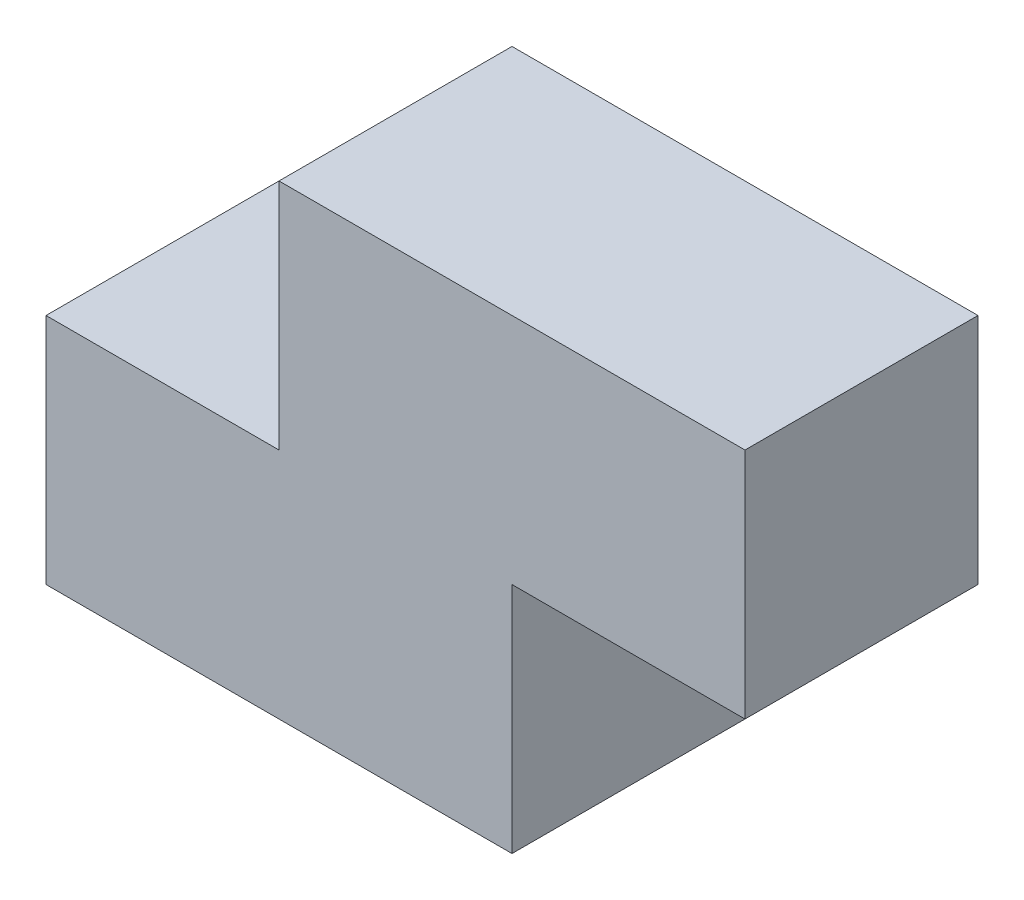
from build123d import *

# Parameters (mm, degrees)
BOSS_EXTRUDE1_DEPTH = 30


with BuildPart() as part:
    # Sketch1 → Boss-Extrude1 (new body)
    with BuildSketch(Plane.XY):
        Polygon((0, 0), (60, 0), (60, 30), (90, 30), (90, 60), (30, 60), (30, 30), (0, 30), align=None)
    extrude(amount=BOSS_EXTRUDE1_DEPTH)


solid = part.part
